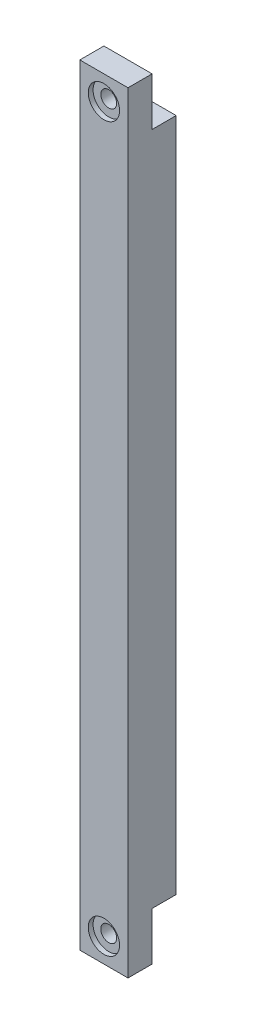
from build123d import *

# Parameters (mm, degrees)
SKETCH_1_W          = 10
SKETCH_1_H          = 160
EXTRUDE_1_DEPTH     = 10
SKETCH_3_W          = 10
SKETCH_3_H          = 10
CUT_EXTRUDE_1_DEPTH = 5
HOLE_WIZARD_M4_1_D  = 3.3
SKETCH_7_R          = 3.25
CUT_EXTRUDE_2_DEPTH = 1


with BuildPart() as part:
    # 草图1 → 凸台-拉伸1 (new body)
    with BuildSketch(Plane.XY):
        with Locations((5, -80)):
            Rectangle(SKETCH_1_W, SKETCH_1_H)
    extrude(amount=EXTRUDE_1_DEPTH)

    # 草图3 → 切除-拉伸1 (cut)
    with BuildSketch(Plane(origin=(0, 0, 0), x_dir=(-1, 0, 0), z_dir=(0, 0, -1))):
        with Locations((-5, -5)):
            Rectangle(SKETCH_3_W, SKETCH_3_H)
        with Locations((-5, -155)):
            Rectangle(SKETCH_3_W, SKETCH_3_H)
    extrude(amount=-CUT_EXTRUDE_1_DEPTH, mode=Mode.SUBTRACT)

    # M4 螺纹孔的螺纹孔钻头1 (through all)
    with Locations(Plane.XY.offset(10)):
        with Locations((5, -5), (5, -155)):
            Hole(HOLE_WIZARD_M4_1_D / 2)

    # 草图7 → 切除-拉伸2 (cut)
    with BuildSketch(Plane.XY.offset(10)):
        with Locations((5, -5)):
            Circle(SKETCH_7_R)
        with Locations((5, -155)):
            Circle(SKETCH_7_R)
    extrude(amount=-CUT_EXTRUDE_2_DEPTH, mode=Mode.SUBTRACT)


solid = part.part
